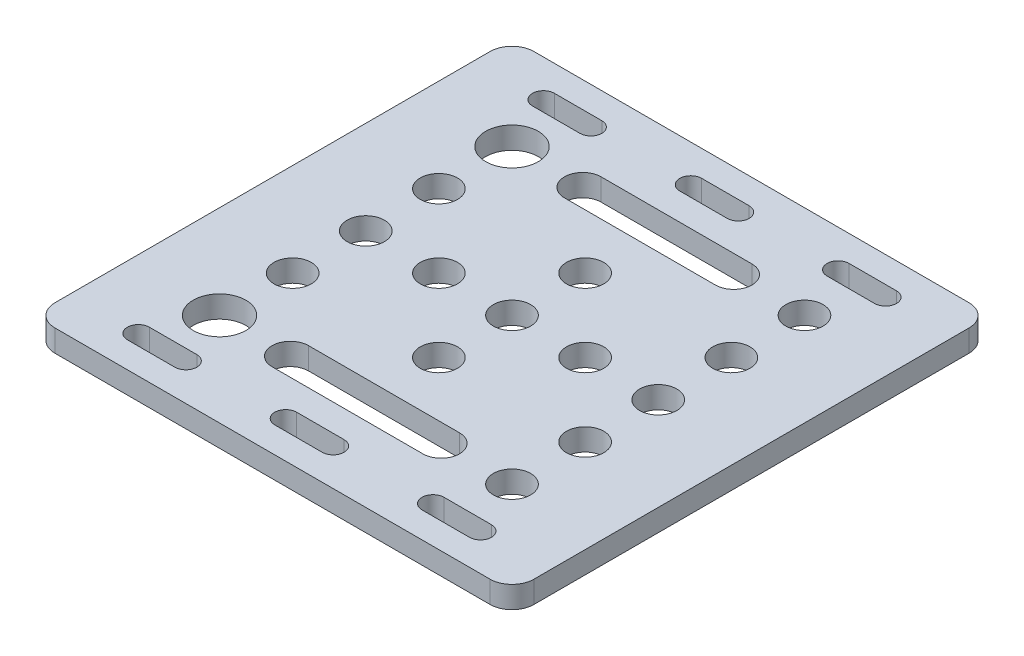
from build123d import *

# Parameters (mm, degrees)
SKETCH1_W           = 65.5
SKETCH1_H           = 65.5
SKETCH1_R           = 3.6
SKETCH1_R_2         = 2.55
BOSS_EXTRUDE1_DEPTH = 3
FILLET2_R           = 3


with BuildPart() as part:
    # Sketch1 → Boss-Extrude1 (new body)
    with BuildSketch(Plane(origin=(0, 0, 0), x_dir=(1, 0, 0), z_dir=(0, 1, 0))):
        Rectangle(SKETCH1_W, SKETCH1_H)
        with BuildLine():
            Line((-16.9, -29.191507266), (-16.9, -29.2))
            Line((-16.9, -29.2), (-23.4, -29.2))
            ThreePointArc((-23.4, -29.2), (-24.9, -27.7), (-23.4, -26.2))
            Line((-23.4, -26.2), (-16.9, -26.2))
            Line((-16.9, -26.2), (-16.9, -26.208492734))
            ThreePointArc((-16.9, -26.208492734), (-15.845345098, -26.645345098), (-15.408492734, -27.7))
            ThreePointArc((-15.408492734, -27.7), (-15.845345098, -28.754654902), (-16.9, -29.191507266))
        make_face(mode=Mode.SUBTRACT)
        with Locations((-20, -20)):
            Circle(SKETCH1_R, mode=Mode.SUBTRACT)
        with BuildLine():
            Line((-3.25, -26.2), (3.25, -26.2))
            Line((3.25, -26.2), (3.25, -26.208492734))
            ThreePointArc((3.25, -26.208492734), (4.304654902, -26.645345098), (4.741507266, -27.7))
            ThreePointArc((4.741507266, -27.7), (4.304654902, -28.754654902), (3.25, -29.191507266))
            Line((3.25, -29.191507266), (3.25, -29.2))
            Line((3.25, -29.2), (-3.25, -29.2))
            ThreePointArc((-3.25, -29.2), (-4.75, -27.7), (-3.25, -26.2))
        make_face(mode=Mode.SUBTRACT)
        with BuildLine():
            Line((-10.32, -17.5), (10.32, -17.5))
            ThreePointArc((10.32, -17.5), (12.087766953, -18.232233047), (12.82, -20))
            ThreePointArc((12.82, -20), (12.087766953, -21.767766953), (10.32, -22.5))
            Line((10.32, -22.5), (-10.32, -22.5))
            ThreePointArc((-10.32, -22.5), (-12.82, -20), (-10.32, -17.5))
        make_face(mode=Mode.SUBTRACT)
        with Locations((-20, -10)):
            Circle(SKETCH1_R_2, mode=Mode.SUBTRACT)
        with Locations((0, -10)):
            Circle(SKETCH1_R_2, mode=Mode.SUBTRACT)
        with BuildLine():
            Line((23.4, -29.191507266), (23.4, -29.2))
            Line((23.4, -29.2), (16.9, -29.2))
            ThreePointArc((16.9, -29.2), (15.4, -27.7), (16.9, -26.2))
            Line((16.9, -26.2), (23.4, -26.2))
            Line((23.4, -26.2), (23.4, -26.208492734))
            ThreePointArc((23.4, -26.208492734), (24.454654902, -26.645345098), (24.891507266, -27.7))
            ThreePointArc((24.891507266, -27.7), (24.454654902, -28.754654902), (23.4, -29.191507266))
        make_face(mode=Mode.SUBTRACT)
        with Locations((20, -20)):
            Circle(SKETCH1_R_2, mode=Mode.SUBTRACT)
        Circle(SKETCH1_R_2, mode=Mode.SUBTRACT)
        with Locations((20, -10)):
            Circle(SKETCH1_R_2, mode=Mode.SUBTRACT)
        with Locations((-20, 0)):
            Circle(SKETCH1_R_2, mode=Mode.SUBTRACT)
        with Locations((-20, 10)):
            Circle(SKETCH1_R_2, mode=Mode.SUBTRACT)
        with Locations((-10, 0)):
            Circle(SKETCH1_R_2, mode=Mode.SUBTRACT)
        with Locations((-20, 20)):
            Circle(SKETCH1_R, mode=Mode.SUBTRACT)
        with BuildLine():
            Line((-23.4, 29.2), (-16.9, 29.2))
            Line((-16.9, 29.2), (-16.9, 29.191507266))
            ThreePointArc((-16.9, 29.191507266), (-15.845345098, 28.754654902), (-15.408492734, 27.7))
            ThreePointArc((-15.408492734, 27.7), (-15.845345098, 26.645345098), (-16.9, 26.208492734))
            Line((-16.9, 26.208492734), (-16.9, 26.2))
            Line((-16.9, 26.2), (-23.4, 26.2))
            ThreePointArc((-23.4, 26.2), (-24.9, 27.7), (-23.4, 29.2))
        make_face(mode=Mode.SUBTRACT)
        with BuildLine():
            Line((-10.32, 22.5), (10.32, 22.5))
            ThreePointArc((10.32, 22.5), (12.087766953, 21.767766953), (12.82, 20))
            ThreePointArc((12.82, 20), (12.087766953, 18.232233047), (10.32, 17.5))
            Line((10.32, 17.5), (-10.32, 17.5))
            ThreePointArc((-10.32, 17.5), (-12.82, 20), (-10.32, 22.5))
        make_face(mode=Mode.SUBTRACT)
        with BuildLine():
            Line((-3.25, 29.2), (3.25, 29.2))
            Line((3.25, 29.2), (3.25, 29.191507266))
            ThreePointArc((3.25, 29.191507266), (4.304654902, 28.754654902), (4.741507266, 27.7))
            ThreePointArc((4.741507266, 27.7), (4.304654902, 26.645345098), (3.25, 26.208492734))
            Line((3.25, 26.208492734), (3.25, 26.2))
            Line((3.25, 26.2), (-3.25, 26.2))
            ThreePointArc((-3.25, 26.2), (-4.75, 27.7), (-3.25, 29.2))
        make_face(mode=Mode.SUBTRACT)
        with Locations((10, 0)):
            Circle(SKETCH1_R_2, mode=Mode.SUBTRACT)
        with Locations((0, 10)):
            Circle(SKETCH1_R_2, mode=Mode.SUBTRACT)
        with Locations((20, 0)):
            Circle(SKETCH1_R_2, mode=Mode.SUBTRACT)
        with Locations((20, 10)):
            Circle(SKETCH1_R_2, mode=Mode.SUBTRACT)
        with Locations((20, 20)):
            Circle(SKETCH1_R_2, mode=Mode.SUBTRACT)
        with BuildLine():
            Line((16.9, 29.2), (23.4, 29.2))
            Line((23.4, 29.2), (23.4, 29.191507266))
            ThreePointArc((23.4, 29.191507266), (24.454654902, 28.754654902), (24.891507266, 27.7))
            ThreePointArc((24.891507266, 27.7), (24.454654902, 26.645345098), (23.4, 26.208492734))
            Line((23.4, 26.208492734), (23.4, 26.2))
            Line((23.4, 26.2), (16.9, 26.2))
            ThreePointArc((16.9, 26.2), (15.4, 27.7), (16.9, 29.2))
        make_face(mode=Mode.SUBTRACT)
    extrude(amount=BOSS_EXTRUDE1_DEPTH)

    # Fillet2
    fillet2_edges = [part.edges().sort_by_distance(p)[0] for p in [
        (-32.75, 1.5, -32.75),
        (32.75, 1.5, -32.75),
        (32.75, 1.5, 32.75),
        (-32.75, 1.5, 32.75),
    ]]
    fillet(fillet2_edges, radius=FILLET2_R)


solid = part.part
